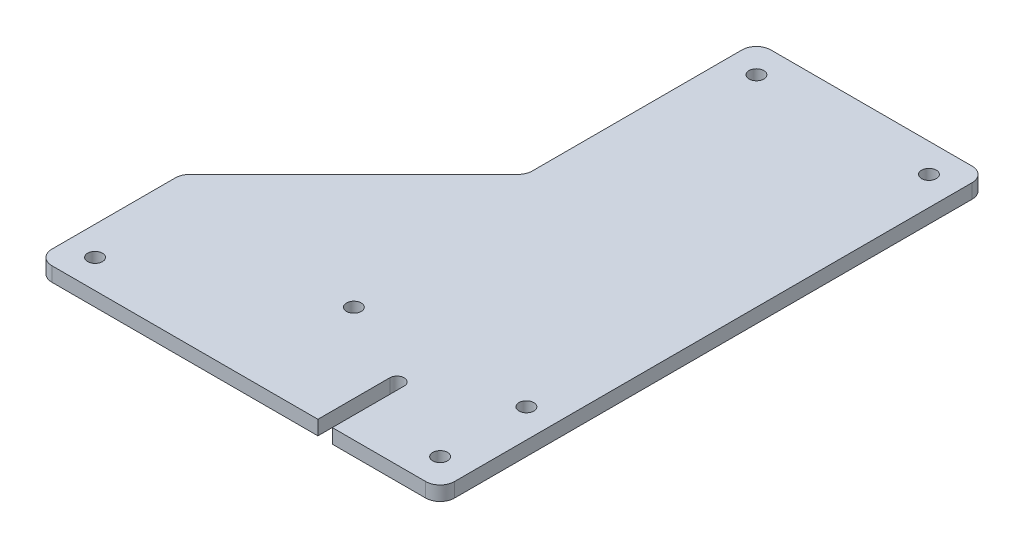
from build123d import *

# Parameters (mm, degrees)
BOSS_EXTRUDE1_DEPTH         = 6.35
F_1_4_CLEARANCE_HOLE1_D     = 6.5278
F_1_4_CLEARANCE_HOLE1_DEPTH = 6.35
F_1_4_CLEARANCE_HOLE1_TIP   = 1.961148974
FILLET1_R                   = 6.35
CUT_EXTRUDE1_REACH          = 8.35


with BuildPart() as part:
    # Sketch1 → Boss-Extrude1 (new body)
    with BuildSketch(Plane(origin=(0, 0, 0), x_dir=(1, 0, 0), z_dir=(0, 1, 0))):
        Polygon((-12.7, 228.6), (88.9, 228.6), (88.9, -12.7), (-88.9, -12.7), (-88.9, 50.8), (-12.7, 127), align=None)
    extrude(amount=BOSS_EXTRUDE1_DEPTH)

    # 1/4 Clearance Hole1
    with Locations(Plane(origin=(0, 6.35, 0), x_dir=(1, 0, 0), z_dir=(0, 1, 0))):
        with Locations((76.2, 215.9), (0, 215.9), (0, 38.1), (76.2, 38.1), (76.2, 0), (-76.2, 0)):
            Hole(F_1_4_CLEARANCE_HOLE1_D / 2, depth=F_1_4_CLEARANCE_HOLE1_DEPTH)
            with Locations((0, 0, -(F_1_4_CLEARANCE_HOLE1_DEPTH + F_1_4_CLEARANCE_HOLE1_TIP / 2))):  # 118° drill point
                Cone(0, F_1_4_CLEARANCE_HOLE1_D / 2, F_1_4_CLEARANCE_HOLE1_TIP, mode=Mode.SUBTRACT)

    # Fillet1
    fillet1_edges = [part.edges().sort_by_distance(p)[0] for p in [
        (-12.7, 3.175, -228.6),
        (88.9, 3.175, -228.6),
        (88.9, 3.175, 12.7),
        (-88.9, 3.175, 12.7),
        (-88.9, 3.175, -50.8),
        (-12.7, 3.175, -127),
    ]]
    fillet(fillet1_edges, radius=FILLET1_R)

    # Sketch4 → Cut-Extrude1 (cut, up to next)
    with BuildSketch(Plane(origin=(0, 6.35, 0), x_dir=(1, 0, 0), z_dir=(0, 1, 0)), mode=Mode.PRIVATE) as cut_extrude1_sk1:
        with BuildLine():
            Line((41.275, 19.05), (41.275, -12.7))
            ThreePointArc((41.275, -12.7), (38.1, -15.875), (34.925, -12.7))
            Line((34.925, -12.7), (34.925, 19.05))
            ThreePointArc((34.925, 19.05), (38.1, 22.225), (41.275, 19.05))
        make_face()
    cut_extrude1_tool1 = extrude(cut_extrude1_sk1.sketch, amount=-CUT_EXTRUDE1_REACH, mode=Mode.PRIVATE) & part.part
    add(cut_extrude1_tool1.solids().sort_by_distance((38.1, 6.35, -3.175))[0], mode=Mode.SUBTRACT)


solid = part.part
